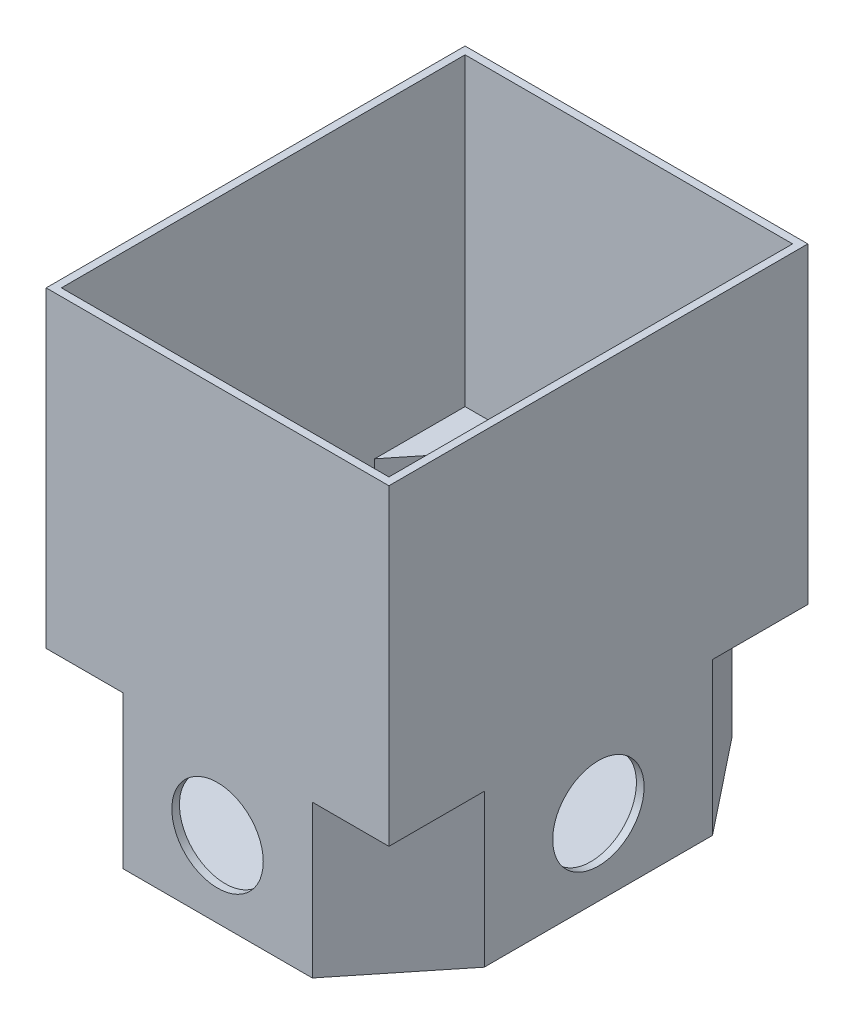
from build123d import *

# Parameters (mm, degrees)
SKETCH1_W           = 90
SKETCH1_H           = 110
BOSS_EXTRUDE1_DEPTH = 82
CUT_EXTRUDE1_DEPTH  = 80
BOSS_EXTRUDE2_DEPTH = 40
CUT_EXTRUDE2_DEPTH  = 40
SKETCH11_R          = 12
CUT_EXTRUDE3_DEPTH  = 94
SKETCH12_R          = 12.003282012
CUT_EXTRUDE4_DEPTH  = 113


with BuildPart() as part:
    # Sketch1 → Boss-Extrude1 (new body)
    with BuildSketch(Plane(origin=(0, 0, 0), x_dir=(1, 0, 0), z_dir=(0, 1, 0))):
        with Locations((-14.558423382, 3.303288505)):
            Rectangle(SKETCH1_W, SKETCH1_H)
    extrude(amount=BOSS_EXTRUDE1_DEPTH)

    # 3DSketch1 → Cut-Extrude1 (cut)
    with BuildSketch(Plane(origin=(28.441576618, 82, 49.696711495), x_dir=(-0.6300408568675958, 0, -0.7765619863716906), z_dir=(0, 1, 0))):
        Polygon((0, 0), (82.315570555, -66.784330828), (136.499084246, 0), (54.183513691, 66.784330828), align=None)
    extrude(amount=-CUT_EXTRUDE1_DEPTH, mode=Mode.SUBTRACT)

    # Sketch7 → Boss-Extrude2 (add)
    with BuildSketch(Plane.XZ):
        Polygon((30.441576618, 26.660546429), (30.441576618, -33.267123439), (10.560534859, -58.303288505), (-39.439465141, -58.303288505), (-59.558423382, -33.267123439), (-59.558423382, 26.660546429), (-39.439465141, 51.696711495), (10.322618378, 51.696711495), align=None)
    extrude(amount=BOSS_EXTRUDE2_DEPTH)

    # Sketch10 → Cut-Extrude2 (cut)
    with BuildSketch(Plane(origin=(0, 2, 0), x_dir=(1, 0, 0), z_dir=(0, 1, 0))):
        Polygon((28.441576618, -25.9565253), (28.441576618, 32.569615498), (9.594834599, 56.303288505), (-38.480908378, 56.303288505), (-57.558423382, 32.563102309), (-57.558423382, -25.9565253), (-38.480908378, -49.696711495), (9.364061615, -49.696711495), align=None)
    extrude(amount=-CUT_EXTRUDE2_DEPTH, mode=Mode.SUBTRACT)

    # Sketch11 → Cut-Extrude3 (cut)
    with BuildSketch(Plane(origin=(30.441576618, 0, 0), x_dir=(0, 0, -1), z_dir=(1, 0, 0))):
        with Locations((3.303288505, -20)):
            Circle(SKETCH11_R)
    extrude(amount=-CUT_EXTRUDE3_DEPTH, mode=Mode.SUBTRACT)

    # Sketch12 → Cut-Extrude4 (cut)
    with BuildSketch(Plane.XY.offset(51.696711495)):
        with Locations((-14.558423382, -20)):
            Circle(SKETCH12_R)
    extrude(amount=-CUT_EXTRUDE4_DEPTH, mode=Mode.SUBTRACT)


solid = part.part
